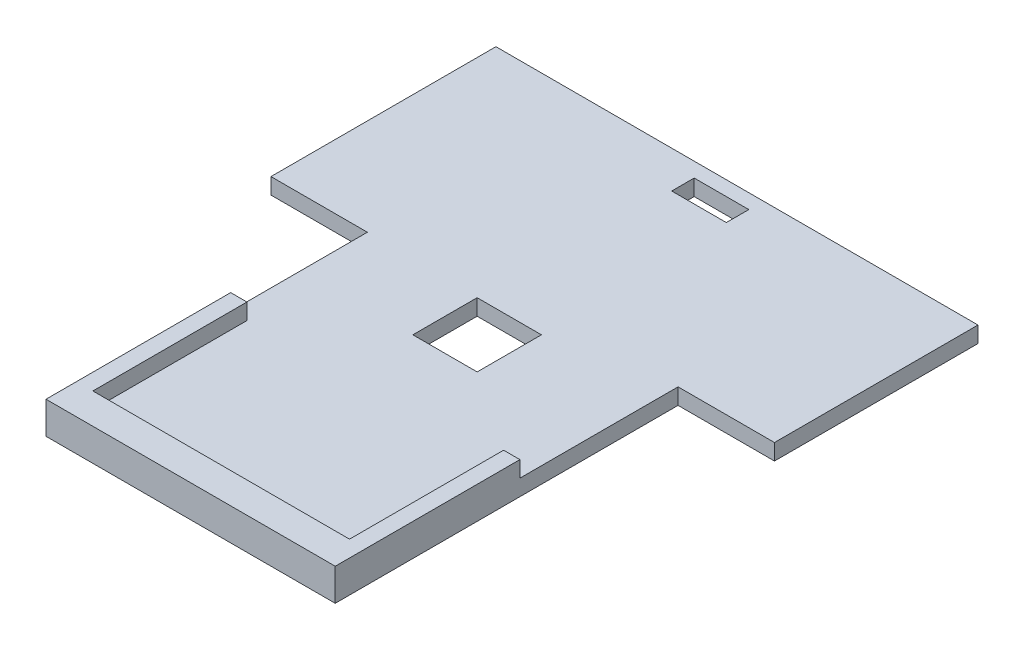
from build123d import *

# Parameters (mm, degrees)
SKETCH2_W           = 17
SKETCH2_H           = 7
BOSS_EXTRUDE1_DEPTH = 5
SKETCH3_W           = 20
SKETCH3_H           = 20
CUT_EXTRUDE1_DEPTH  = 5
BOSS_EXTRUDE2_DEPTH = 5


with BuildPart() as part:
    # Sketch2 → Boss-Extrude1 (new body)
    with BuildSketch(Plane(origin=(0, 0, 0), x_dir=(1, 0, 0), z_dir=(0, 1, 0))):
        Polygon((-44.718981883, -89.435737216), (45.281018117, -89.435737216), (45.281018117, 17.235484445), (75.281018117, 17.235484445), (75.281018117, 80.564262784), (-74.718981883, 80.564262784), (-74.718981883, 10.564262784), (-44.718981883, 10.564262784), align=None)
        with Locations((0.021018117, 72.514262784)):
            Rectangle(SKETCH2_W, SKETCH2_H, mode=Mode.SUBTRACT)
    extrude(amount=BOSS_EXTRUDE1_DEPTH)

    # Sketch3 → Cut-Extrude1 (cut)
    with BuildSketch(Plane(origin=(0, 5, 0), x_dir=(1, 0, 0), z_dir=(0, 1, 0))):
        Rectangle(SKETCH3_W, SKETCH3_H)
    extrude(amount=-CUT_EXTRUDE1_DEPTH, mode=Mode.SUBTRACT)

    # Sketch5 → Boss-Extrude2 (add)
    with BuildSketch(Plane(origin=(0, 5, 0), x_dir=(1, 0, 0), z_dir=(0, 1, 0))):
        Polygon((-39.650543722, -79.921839448), (40.212579957, -79.921839448), (40.212579957, -31.975199113), (45.281018117, -31.975199113), (45.281018117, -79.921839448), (45.281018117, -89.435737216), (-44.718981883, -89.435737216), (-44.718981883, -79.921839448), (-44.718981883, -31.975199113), (-39.650543722, -31.975199113), align=None)
    extrude(amount=BOSS_EXTRUDE2_DEPTH)


solid = part.part
